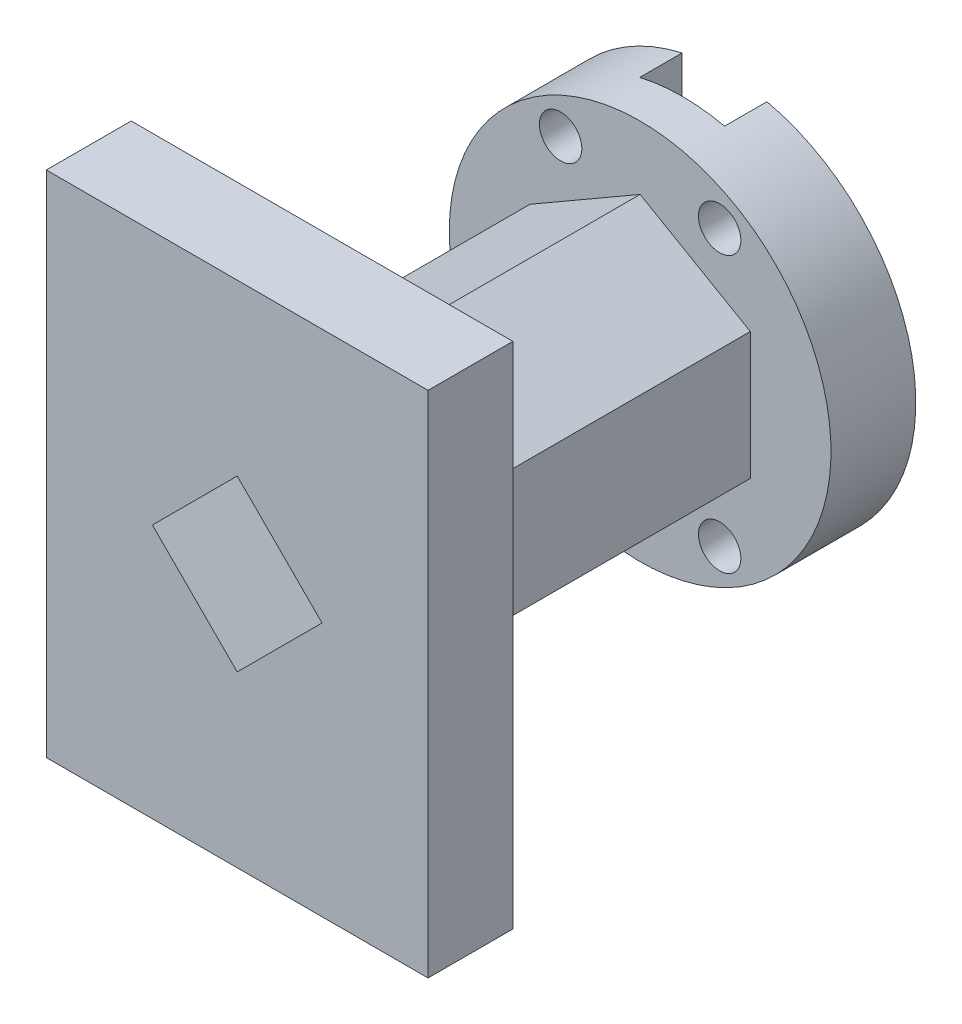
from build123d import *

# Parameters (mm, degrees)
SKETCH2_W           = 90
SKETCH2_H           = 120
BOSS_EXTRUDE4_DEPTH = 20
BOSS_EXTRUDE5_DEPTH = 75
SKETCH20_R          = 45
BOSS_EXTRUDE6_DEPTH = 20
SKETCH21_W          = 20
SKETCH21_H          = 100
BOSS_EXTRUDE8_DEPTH = 10
SKETCH26_R          = 5
CUT_EXTRUDE2_DEPTH  = 20
CUT_EXTRUDE3_DEPTH  = 115


with BuildPart() as part:
    # Sketch2 → Boss-Extrude4 (new body)
    with BuildSketch(Plane.XY):
        with Locations((-78.096450442, 37.501466256)):
            Rectangle(SKETCH2_W, SKETCH2_H)
    extrude(amount=BOSS_EXTRUDE4_DEPTH)

    # Sketch19 → Boss-Extrude5 (add)
    with BuildSketch(Plane(origin=(0, 0, 0), x_dir=(-1, 0, 0), z_dir=(0, 0, -1))):
        Polygon((78.096450442, 67.501466256), (52.115688328, 52.501466256), (52.115688328, 22.501466256), (78.096450442, 7.501466256), (104.077212555, 22.501466256), (104.077212555, 52.501466256), align=None)
    extrude(amount=BOSS_EXTRUDE5_DEPTH)

    # Sketch20 → Boss-Extrude6 (add)
    with BuildSketch(Plane(origin=(0, 0, -75), x_dir=(-1, 0, 0), z_dir=(0, 0, -1))):
        with Locations((78.096450442, 37.501466256)):
            Circle(SKETCH20_R)
    extrude(amount=BOSS_EXTRUDE6_DEPTH)


with BuildPart() as body_2:
    # Sketch21 → Boss-Extrude8 (new body)
    with BuildSketch(Plane(origin=(0, 0, -95), x_dir=(-1, 0, 0), z_dir=(0, 0, -1))):
        with Locations((78.183292606, 37.571308656)):
            Rectangle(SKETCH21_W, SKETCH21_H)
    extrude(amount=-BOSS_EXTRUDE8_DEPTH)


with BuildPart() as part_1:
    add(part.part)

    # Combine1: cut body 2
    add(body_2.part, mode=Mode.SUBTRACT)

    # Sketch26 → Cut-Extrude2 (cut)
    with BuildSketch(Plane(origin=(0, 0, -95), x_dir=(-1, 0, 0), z_dir=(0, 0, -1))):
        with Locations((59.346450442, 69.977418898)):
            Circle(SKETCH26_R)
        with Locations((96.846450442, 69.977418898)):
            Circle(SKETCH26_R)
        with Locations((59.346450442, 5.025513614)):
            Circle(SKETCH26_R)
        with Locations((96.846450442, 5.025513614)):
            Circle(SKETCH26_R)
    extrude(amount=-CUT_EXTRUDE2_DEPTH, mode=Mode.SUBTRACT)

    # Sketch28 → Cut-Extrude3 (cut)
    with BuildSketch(Plane.XY.offset(20)):
        Polygon((-58.096450442, 37.501466256), (-78.096450442, 57.501466256), (-98.096450442, 37.501466256), (-78.096450442, 17.501466256), align=None)
    extrude(amount=-CUT_EXTRUDE3_DEPTH, mode=Mode.SUBTRACT)


solid = part_1.part
